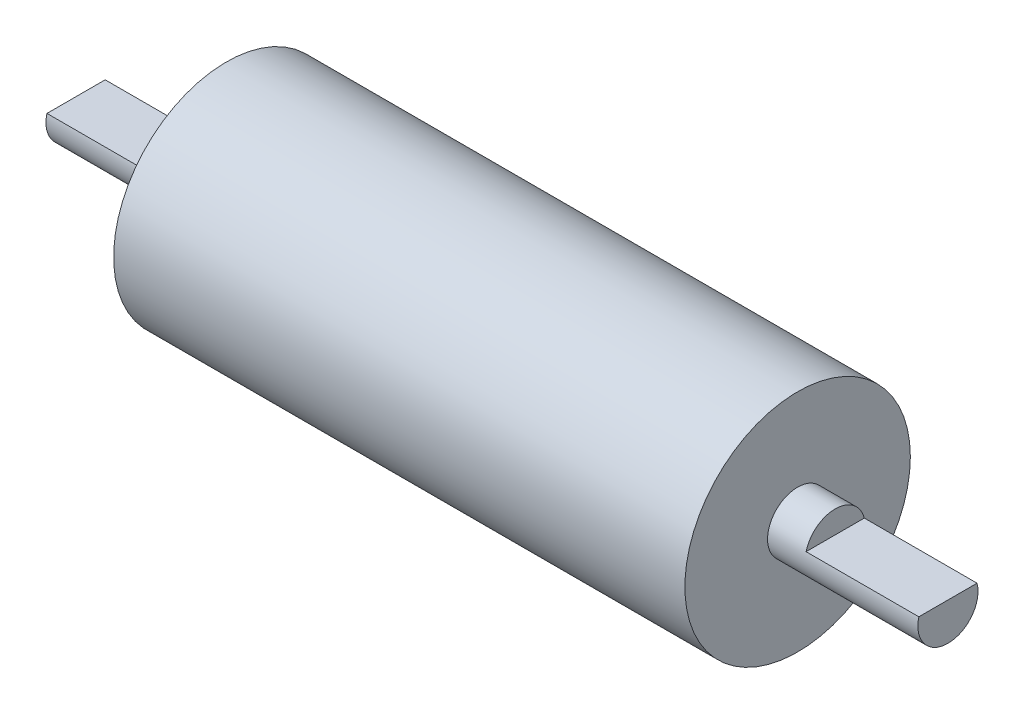
from build123d import *

# Parameters (mm, degrees)
ESBO_O8_R                = 4
RESSALTO_EXTRUS_O4_DEPTH = 20
ESBO_O9_R                = 15
RESSALTO_EXTRUS_O5_DEPTH = 76
ESBO_O10_R               = 4
RESSALTO_EXTRUS_O6_DEPTH = 20
ESBO_O11_W               = 14.978284248
ESBO_O11_H               = 3
CORTE_EXTRUS_O1_DEPTH    = 15
ESBO_O12_W               = 14.281633968
ESBO_O12_H               = 3
CORTE_EXTRUS_O2_DEPTH    = 15


with BuildPart() as part:
    # Esboço8 → Ressalto-extrusão4 (new body)
    with BuildSketch(Plane(origin=(0, 0, 0), x_dir=(0, 0, -1), z_dir=(1, 0, 0))):
        Circle(ESBO_O8_R)
    extrude(amount=RESSALTO_EXTRUS_O4_DEPTH)

    # Esboço9 → Ressalto-extrusão5 (add)
    with BuildSketch(Plane(origin=(20, 0, 0), x_dir=(0, 0, -1), z_dir=(1, 0, 0))):
        Circle(ESBO_O9_R)
    extrude(amount=RESSALTO_EXTRUS_O5_DEPTH)

    # Esboço10 → Ressalto-extrusão6 (add)
    with BuildSketch(Plane(origin=(96, 0, 0), x_dir=(0, 0, -1), z_dir=(1, 0, 0))):
        Circle(ESBO_O10_R)
    extrude(amount=RESSALTO_EXTRUS_O6_DEPTH)

    # Esboço11 → Corte-extrusão1 (cut)
    with BuildSketch(Plane.ZY):
        with Locations((-0.140546903, 2.5)):
            Rectangle(ESBO_O11_W, ESBO_O11_H)
    extrude(amount=-CORTE_EXTRUS_O1_DEPTH, mode=Mode.SUBTRACT)

    # Esboço12 → Corte-extrusão2 (cut)
    with BuildSketch(Plane(origin=(116, 0, 0), x_dir=(0, 0, -1), z_dir=(1, 0, 0))):
        with Locations((0.158049163, 2.5)):
            Rectangle(ESBO_O12_W, ESBO_O12_H)
    extrude(amount=-CORTE_EXTRUS_O2_DEPTH, mode=Mode.SUBTRACT)


solid = part.part
